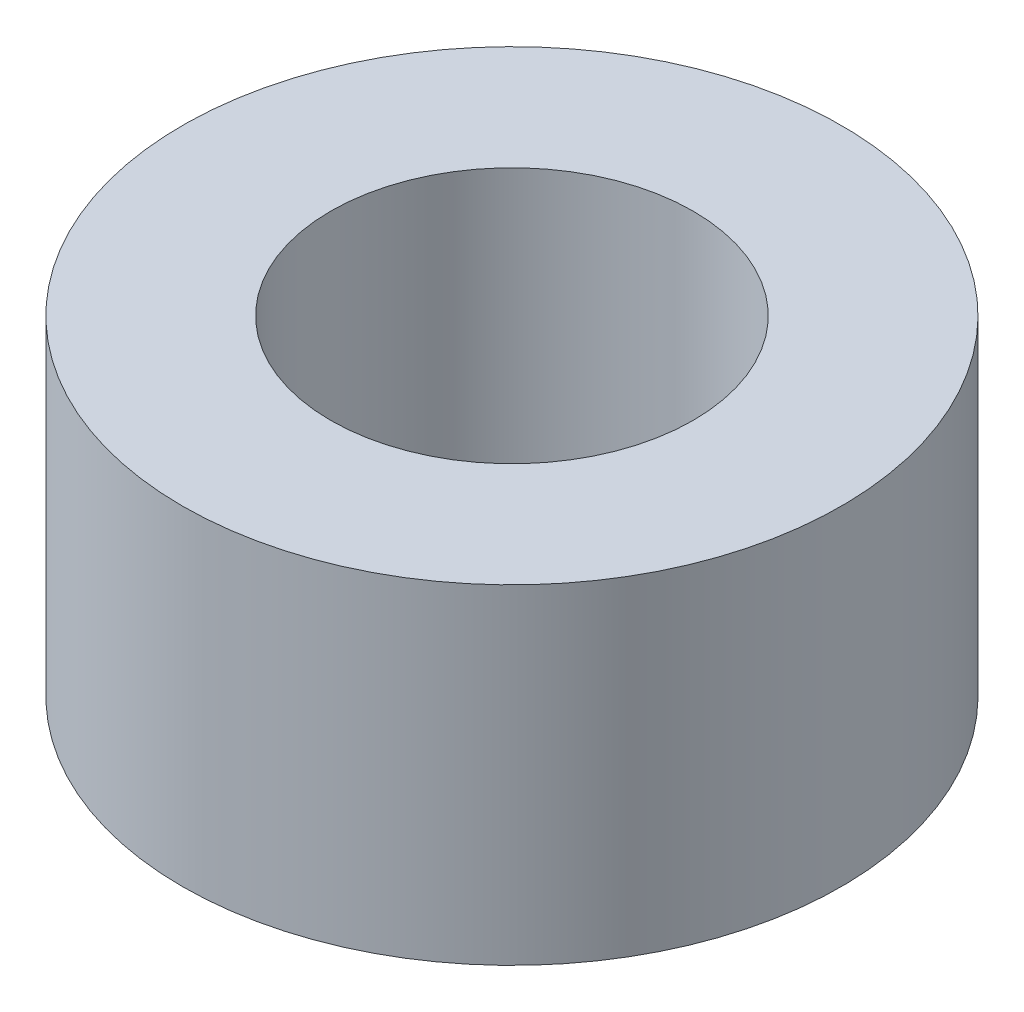
from build123d import *

# Parameters (mm, degrees)
SKETCH_2_R      = 15
EXTRUDE_1_DEPTH = 15
M18X1_0_1_D     = 16.5


with BuildPart() as part:
    # 草图2 → 凸台-拉伸1 (new body)
    with BuildSketch(Plane(origin=(0, 0, 0), x_dir=(1, 0, 0), z_dir=(0, 1, 0))):
        Circle(SKETCH_2_R)
    extrude(amount=EXTRUDE_1_DEPTH)

    # M18x1.0 螺纹孔1 (through all)
    with Locations(Plane(origin=(0, 15, 0), x_dir=(1, 0, 0), z_dir=(0, 1, 0))):
        with Locations((0, 0)):
            Hole(M18X1_0_1_D / 2)


solid = part.part
